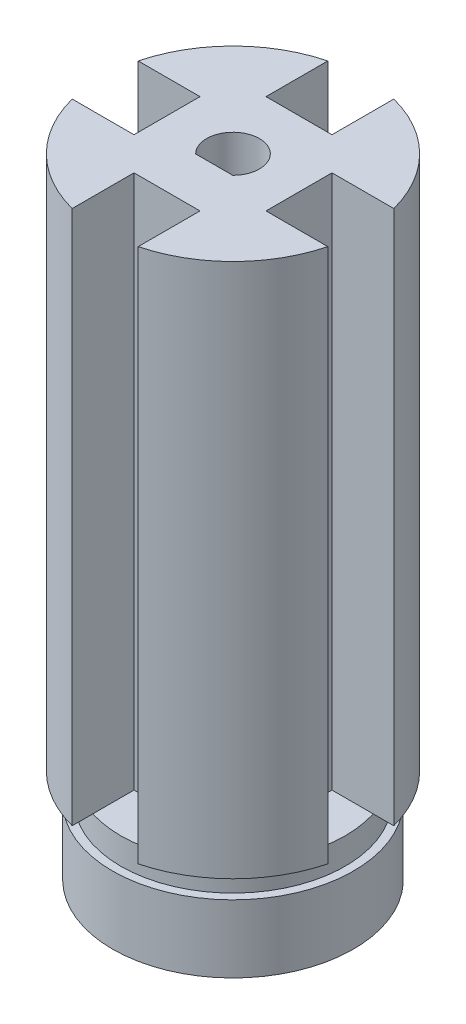
from build123d import *

# Parameters (mm, degrees)
BOSS_EXTRUDE8_DEPTH           = 0.255
BOSS_EXTRUDE8_DEPTH_BACK      = 10
SKETCH13_R                    = 18.25
SKETCH13_R_2                  = 17
SKETCH14_R                    = 17
SKETCH14_R_2                  = 4
BOSS_EXTRUDE17_DEPTH          = 5
CONNECTOR_CYLINDER_DEPTH      = 80
CONNECTOR_CYLINDER_DEPTH_BACK = 1
SKETCH21_R                    = 20
SKETCH23_R                    = 4
CUT_EXTRUDE4_DEPTH            = 96.3
CONNECTOR_CYLINDER_CUT_DEPTH  = 81
KEY_CUT_DEPTH                 = 85


with BuildPart() as part:
    # Sketch13 → Boss-Extrude8 (new, two sides: drawn at the far end of the back side and taken through both)
    with BuildSketch(Plane(origin=(0, 0, 0), x_dir=(1, 0, 0), z_dir=(0, 1, 0)).offset(-BOSS_EXTRUDE8_DEPTH_BACK)):
        with Locations(Location((0, 0, 0), (0, 0, 270))):
            Circle(SKETCH13_R)
        with Locations(Location((0, 0, 0), (0, 0, 270))):
            Circle(SKETCH13_R_2, mode=Mode.SUBTRACT)
    extrude(amount=BOSS_EXTRUDE8_DEPTH + BOSS_EXTRUDE8_DEPTH_BACK)


with BuildPart() as body_2:
    # Sketch14 → Boss-Extrude17 (new body)
    # profile 1 of 2: a face of its own
    with BuildSketch(Plane(origin=(0, 0.255, 0), x_dir=(1, 0, 0), z_dir=(0, 1, 0))):
        with Locations(Location((0, 0, 0), (0, 0, 270))):
            Circle(SKETCH14_R)
        Circle(SKETCH14_R_2, mode=Mode.SUBTRACT)
    # profile 2 of 2: a face of its own
    with BuildSketch(Plane(origin=(0, 0.255, 0), x_dir=(1, 0, 0), z_dir=(0, 1, 0))):
        with BuildLine():
            ThreePointArc((2.066246597, 3.425), (0, 4), (-2.066246597, 3.425))
            Line((-2.066246597, 3.425), (0, 3.425))
            Line((0, 3.425), (2.066246597, 3.425))
        make_face()
    extrude(amount=BOSS_EXTRUDE17_DEPTH)

    # Sketch21 → Connector Cylinder (add, two sides: drawn at the far end of the back side and taken through both)
    with BuildSketch(Plane(origin=(0, 5.255, 0), x_dir=(1, 0, 0), z_dir=(0, 1, 0)).offset(-CONNECTOR_CYLINDER_DEPTH_BACK)):
        with Locations(Location((0, 0, 0), (0, 0, 270))):
            Circle(SKETCH21_R)
    extrude(amount=CONNECTOR_CYLINDER_DEPTH + CONNECTOR_CYLINDER_DEPTH_BACK)

    # Sketch23 → Cut-Extrude4 (cut)
    with BuildSketch(Plane(origin=(0, 85.255, 0), x_dir=(1, 0, 0), z_dir=(0, 1, 0))):
        with Locations(Location((0, 0, 0), (0, 0, 270))):
            Circle(SKETCH23_R)
    extrude(amount=-CUT_EXTRUDE4_DEPTH, mode=Mode.SUBTRACT)

    # Sketch22 → Connector Cylinder Cut (cut)
    with BuildSketch(Plane(origin=(0, 85.255, 0), x_dir=(1, 0, 0), z_dir=(0, 1, 0))):
        with BuildLine():
            ThreePointArc((-5, -19.364916731), (0, -20), (5, -19.364916731))
            Line((5, -19.364916731), (5, -10))
            Line((5, -10), (-5, -10))
            Line((-5, -10), (-5, -19.364916731))
        make_face()
        with BuildLine():
            ThreePointArc((-19.364916731, 5), (-20, 0), (-19.364916731, -5))
            Line((-19.364916731, -5), (-10, -5))
            Line((-10, -5), (-10, 5))
            Line((-10, 5), (-19.364916731, 5))
        make_face()
        with BuildLine():
            Line((5, 10), (5, 19.364916731))
            ThreePointArc((5, 19.364916731), (0, 20), (-5, 19.364916731))
            Line((-5, 19.364916731), (-5, 10))
            Line((-5, 10), (5, 10))
        make_face()
        with BuildLine():
            Line((9.999996731, 5), (9.999996731, -5))
            Line((9.999996731, -5), (19.364916731, -5))
            ThreePointArc((19.364916731, -5), (19.840593925, -2.52008585), (20, 0))
            ThreePointArc((20, 0), (19.840593925, 2.52008585), (19.364916731, 5))
            Line((19.364916731, 5), (9.999996731, 5))
        make_face()
    extrude(amount=-CONNECTOR_CYLINDER_CUT_DEPTH, mode=Mode.SUBTRACT)

    # Sketch25 → Key Cut (add)
    with BuildSketch(Plane.XZ.offset(-0.255)):
        with BuildLine():
            ThreePointArc((2.80668844, 2.85), (0, 4), (-2.80668844, 2.85))
            Line((-2.80668844, 2.85), (2.80668844, 2.85))
        make_face()
    extrude(amount=-KEY_CUT_DEPTH)


solid = Compound([part.part, body_2.part])
